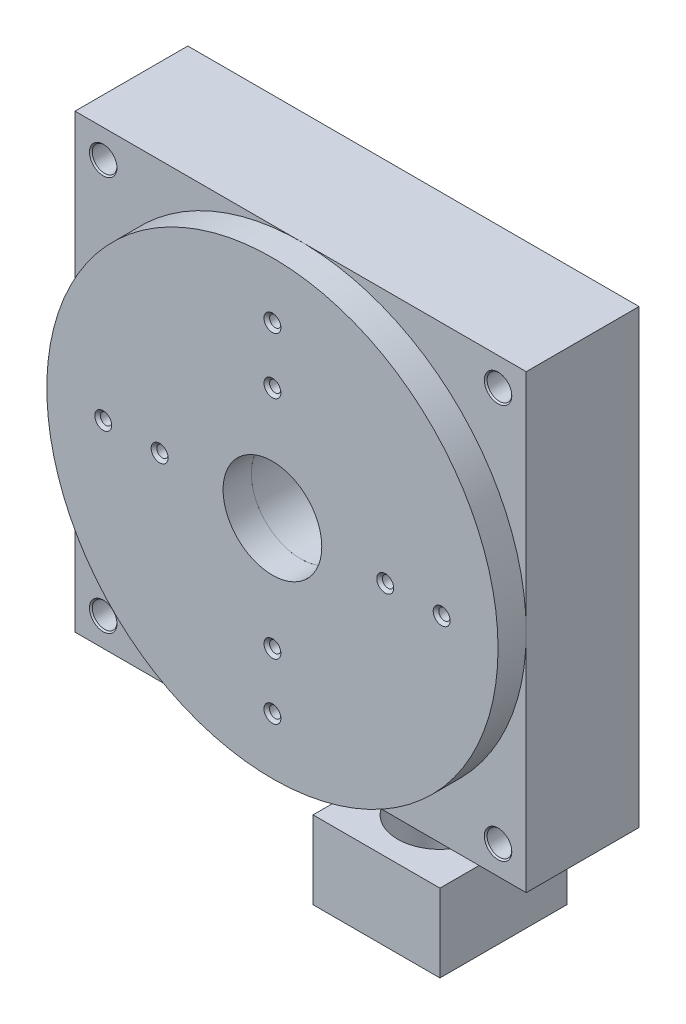
from build123d import *

# Parameters (mm, degrees)
SKETCH1_R                                     = 101.6
SKETCH1_R_2                                   = 22.225
BOSS_EXTRUDE1_DEPTH                           = 12.7
F_1_4_20_TAPPED_HOLE1_AT_2_COUNT              = 2
F_1_4_20_TAPPED_HOLE1_AT_2_PITCH              = 91.581002397
F_1_4_20_TAPPED_HOLE1_AT_3_COUNT              = 2
F_1_4_20_TAPPED_HOLE1_AT_3_PITCH              = 71.842048969
F_1_4_20_TAPPED_HOLE1_AT_4_COUNT              = 2
F_1_4_20_TAPPED_HOLE1_AT_4_PITCH              = 127
F_1_4_20_TAPPED_HOLE1_AT_5_COUNT              = 2
F_1_4_20_TAPPED_HOLE1_AT_5_PITCH              = 101.6
F_1_4_20_TAPPED_HOLE1_AT_6_COUNT              = 2
F_1_4_20_TAPPED_HOLE1_AT_6_PITCH              = 91.581002397
F_1_4_20_TAPPED_HOLE1_AT_7_COUNT              = 2
F_1_4_20_TAPPED_HOLE1_AT_7_PITCH              = 71.842048969
F_1_4_20_TAPPED_HOLE1_AT_8_COUNT              = 2
F_1_4_20_TAPPED_HOLE1_AT_8_PITCH              = 25.4
SKETCH4_W                                     = 203.2
SKETCH4_H                                     = 203.2
SKETCH4_R                                     = 22.225
BOSS_EXTRUDE2_DEPTH                           = 50.8
CBORE_FOR_1_4_SOCKET_HEAD_CAP_SCREW1_AT_COUNT = 2
CBORE_FOR_1_4_SOCKET_HEAD_CAP_SCREW1_AT_PITCH = 251.44717139
CBORE_FOR_1_4_SOCKET_HEAD_CAP_SCREW1_2_COUNT  = 2
CBORE_FOR_1_4_SOCKET_HEAD_CAP_SCREW1_2_PITCH  = 177.8
CBORE_FOR_1_4_SOCKET_HEAD_CAP_SCREW1_3_COUNT  = 2
CBORE_FOR_1_4_SOCKET_HEAD_CAP_SCREW1_3_PITCH  = 177.8
SKETCH7_W                                     = 57.15
SKETCH7_H                                     = 57.15
SKETCH7_R                                     = 19.05
BOSS_EXTRUDE3_DEPTH                           = 35.052
F_10_24_TAPPED_HOLE1_AT_2_COUNT               = 2
F_10_24_TAPPED_HOLE1_AT_2_PITCH               = 66.813105541
F_10_24_TAPPED_HOLE1_AT_3_COUNT               = 2
F_10_24_TAPPED_HOLE1_AT_3_PITCH               = 47.244
F_10_24_TAPPED_HOLE1_AT_4_COUNT               = 2
F_10_24_TAPPED_HOLE1_AT_4_PITCH               = 47.244


with BuildPart() as part:
    # Sketch1 → Boss-Extrude1 (new body)
    with BuildSketch(Plane.XY):
        Circle(SKETCH1_R)
        Circle(SKETCH1_R_2, mode=Mode.SUBTRACT)
    extrude(amount=BOSS_EXTRUDE1_DEPTH)

    # Sketch3 → 1_4-20 Tapped Hole1 (revolve, cut)
    with BuildSketch(Plane(origin=(-50.8, 0, 12.7), x_dir=(0, -1, 0), z_dir=(1, 0, 0))):
        Polygon((0, 0), (0, 12.7), (3.81, 12.7), (2.5527, 11.4427), (2.5527, 1.2573), (3.81, 0), align=None)
    f_1_4_20_tapped_hole1 = revolve(axis=Axis((-50.8, 0, 19.05), (0, 0, -1)), mode=Mode.SUBTRACT)

    # 1_4-20 Tapped Hole1 at 2: 1_4-20 Tapped Hole1 ×2
    with Locations(*[Vector(0.554700196, 0.832050294, 0) * (i * F_1_4_20_TAPPED_HOLE1_AT_2_PITCH) for i in range(1, F_1_4_20_TAPPED_HOLE1_AT_2_COUNT)]):
        add(f_1_4_20_tapped_hole1, mode=Mode.SUBTRACT)

    # 1_4-20 Tapped Hole1 at 3: 1_4-20 Tapped Hole1 ×2
    with Locations(*[Vector(0.707106781, 0.707106781, 0) * (i * F_1_4_20_TAPPED_HOLE1_AT_3_PITCH) for i in range(1, F_1_4_20_TAPPED_HOLE1_AT_3_COUNT)]):
        add(f_1_4_20_tapped_hole1, mode=Mode.SUBTRACT)

    # 1_4-20 Tapped Hole1 at 4: 1_4-20 Tapped Hole1 ×2
    with Locations(*[(i * F_1_4_20_TAPPED_HOLE1_AT_4_PITCH, 0, 0) for i in range(1, F_1_4_20_TAPPED_HOLE1_AT_4_COUNT)]):
        add(f_1_4_20_tapped_hole1, mode=Mode.SUBTRACT)

    # 1_4-20 Tapped Hole1 at 5: 1_4-20 Tapped Hole1 ×2
    with Locations(*[(i * F_1_4_20_TAPPED_HOLE1_AT_5_PITCH, 0, 0) for i in range(1, F_1_4_20_TAPPED_HOLE1_AT_5_COUNT)]):
        add(f_1_4_20_tapped_hole1, mode=Mode.SUBTRACT)

    # 1_4-20 Tapped Hole1 at 6: 1_4-20 Tapped Hole1 ×2
    with Locations(*[Vector(0.554700196, -0.832050294, 0) * (i * F_1_4_20_TAPPED_HOLE1_AT_6_PITCH) for i in range(1, F_1_4_20_TAPPED_HOLE1_AT_6_COUNT)]):
        add(f_1_4_20_tapped_hole1, mode=Mode.SUBTRACT)

    # 1_4-20 Tapped Hole1 at 7: 1_4-20 Tapped Hole1 ×2
    with Locations(*[Vector(0.707106781, -0.707106781, 0) * (i * F_1_4_20_TAPPED_HOLE1_AT_7_PITCH) for i in range(1, F_1_4_20_TAPPED_HOLE1_AT_7_COUNT)]):
        add(f_1_4_20_tapped_hole1, mode=Mode.SUBTRACT)

    # 1_4-20 Tapped Hole1 at 8: 1_4-20 Tapped Hole1 ×2
    with Locations(*[(-i * F_1_4_20_TAPPED_HOLE1_AT_8_PITCH, 0, 0) for i in range(1, F_1_4_20_TAPPED_HOLE1_AT_8_COUNT)]):
        add(f_1_4_20_tapped_hole1, mode=Mode.SUBTRACT)


with BuildPart() as body_2:
    # Sketch4 → Boss-Extrude2 (new body)
    with BuildSketch(Plane(origin=(0, 0, 0), x_dir=(-1, 0, 0), z_dir=(0, 0, -1))):
        Rectangle(SKETCH4_W, SKETCH4_H)
        Circle(SKETCH4_R, mode=Mode.SUBTRACT)
    extrude(amount=BOSS_EXTRUDE2_DEPTH)

    # Sketch6 → CBORE for 1_4 Socket Head Cap Screw1 (revolve, cut)
    with BuildSketch(Plane(origin=(-88.9, -88.9, 0), x_dir=(0, -1, 0), z_dir=(1, 0, 0))):
        Polygon((0, 0), (0, 50.8), (3.8989, 50.8), (3.2639, 50.165), (3.2639, 44.45), (5.55625, 44.45), (5.55625, 0.635), (6.19125, 0), align=None)
    cbore_for_1_4_socket_head_cap_screw1 = revolve(axis=Axis((-88.9, -88.9, 6.35), (0, 0, -1)), mode=Mode.SUBTRACT)

    # CBORE for 1_4 Socket Head Cap Screw1 at: CBORE for 1_4 Socket Head Cap Screw1 ×2
    with Locations(*[Vector(0.707106781, 0.707106781, 0) * (i * CBORE_FOR_1_4_SOCKET_HEAD_CAP_SCREW1_AT_PITCH) for i in range(1, CBORE_FOR_1_4_SOCKET_HEAD_CAP_SCREW1_AT_COUNT)]):
        add(cbore_for_1_4_socket_head_cap_screw1, mode=Mode.SUBTRACT)

    # CBORE for 1_4 Socket Head Cap Screw1 2: CBORE for 1_4 Socket Head Cap Screw1 ×2
    with Locations(*[(i * CBORE_FOR_1_4_SOCKET_HEAD_CAP_SCREW1_2_PITCH, 0, 0) for i in range(1, CBORE_FOR_1_4_SOCKET_HEAD_CAP_SCREW1_2_COUNT)]):
        add(cbore_for_1_4_socket_head_cap_screw1, mode=Mode.SUBTRACT)

    # CBORE for 1_4 Socket Head Cap Screw1 3: CBORE for 1_4 Socket Head Cap Screw1 ×2
    with Locations(*[(0, i * CBORE_FOR_1_4_SOCKET_HEAD_CAP_SCREW1_3_PITCH, 0) for i in range(1, CBORE_FOR_1_4_SOCKET_HEAD_CAP_SCREW1_3_COUNT)]):
        add(cbore_for_1_4_socket_head_cap_screw1, mode=Mode.SUBTRACT)

    # Sketch7 → Boss-Extrude3 (add)
    with BuildSketch(Plane.XZ.offset(101.6)):
        with Locations((51.816, -10.922)):
            Rectangle(SKETCH7_W, SKETCH7_H)
        with Locations((51.816, -10.922)):
            Circle(SKETCH7_R, mode=Mode.SUBTRACT)
    extrude(amount=BOSS_EXTRUDE3_DEPTH)

    # Sketch10 → 10-24 Tapped Hole1 (revolve, cut)
    with BuildSketch(Plane(origin=(28.194, -136.652, 12.7), x_dir=(0, 0, -1), z_dir=(1, 0, 0))):
        Polygon((0, 0), (0, 26.540824014), (1.89865, 25.4), (1.89865, 1.14935), (3.048, 0), align=None)
    f_10_24_tapped_hole1 = revolve(axis=Axis((28.194, -143.002, 12.7), (0, 1, 0)), mode=Mode.SUBTRACT)

    # 10-24 Tapped Hole1 at 2: 10-24 Tapped Hole1 ×2
    with Locations(*[Vector(0.707106781, 0, -0.707106781) * (i * F_10_24_TAPPED_HOLE1_AT_2_PITCH) for i in range(1, F_10_24_TAPPED_HOLE1_AT_2_COUNT)]):
        add(f_10_24_tapped_hole1, mode=Mode.SUBTRACT)

    # 10-24 Tapped Hole1 at 3: 10-24 Tapped Hole1 ×2
    with Locations(*[(i * F_10_24_TAPPED_HOLE1_AT_3_PITCH, 0, 0) for i in range(1, F_10_24_TAPPED_HOLE1_AT_3_COUNT)]):
        add(f_10_24_tapped_hole1, mode=Mode.SUBTRACT)

    # 10-24 Tapped Hole1 at 4: 10-24 Tapped Hole1 ×2
    with Locations(*[(0, 0, -i * F_10_24_TAPPED_HOLE1_AT_4_PITCH) for i in range(1, F_10_24_TAPPED_HOLE1_AT_4_COUNT)]):
        add(f_10_24_tapped_hole1, mode=Mode.SUBTRACT)


solid = Compound([part.part, body_2.part])
